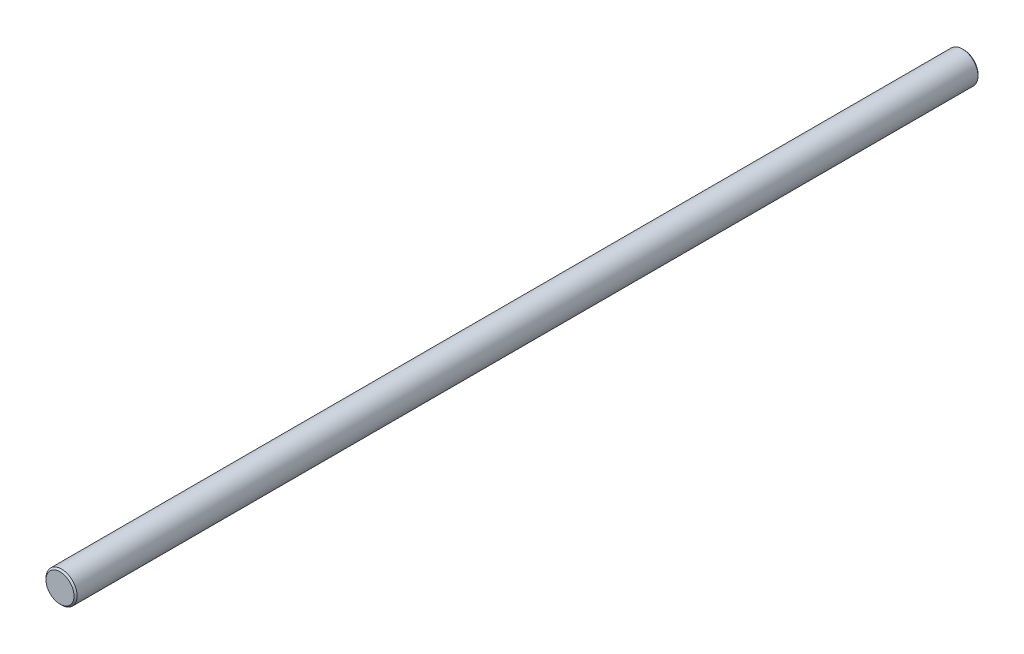
from build123d import *

# Parameters (mm, degrees)
ESBO_O1_R                = 5
RESSALTO_EXTRUS_O1_DEPTH = 290
CHANFRO1_SIZE            = 0.5


with BuildPart() as part:
    # Esboço1 → Ressalto-extrusão1 (new body)
    with BuildSketch(Plane.XY):
        Circle(ESBO_O1_R)
    extrude(amount=RESSALTO_EXTRUS_O1_DEPTH)

    # Chanfro1
    chanfro1_edges = [part.edges().sort_by_distance(p)[0] for p in [
        (-5, 0, 0),
        (-5, 0, 290),
    ]]
    chamfer(chanfro1_edges, length=CHANFRO1_SIZE)


solid = part.part
